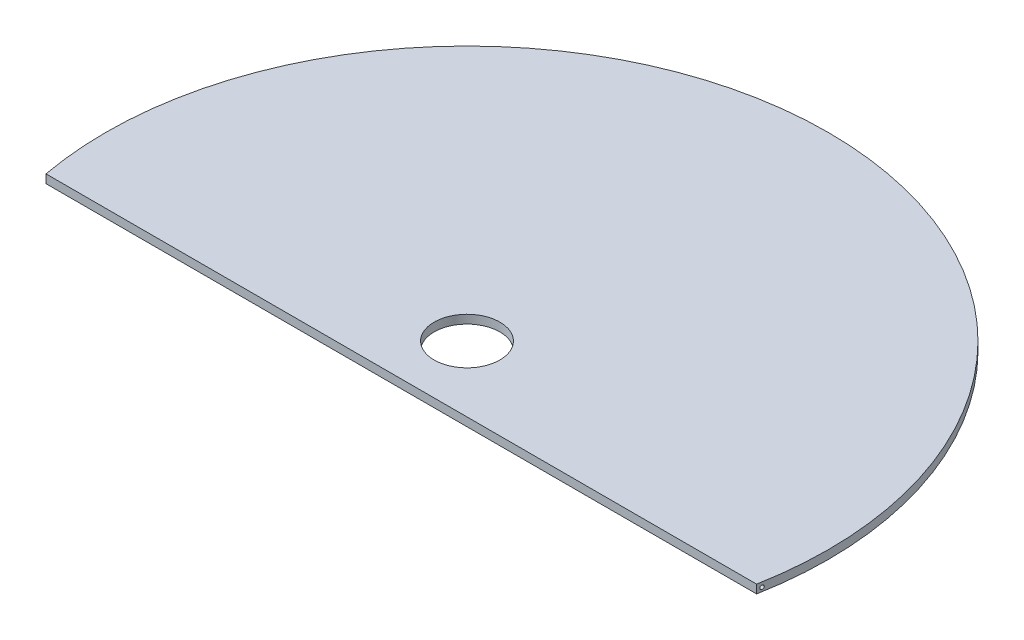
from build123d import *

# Parameters (mm, degrees)
SKETCH1_R               = 12.7
BOSS_EXTRUDE2_DEPTH     = 3.302
SKETCH4_R               = 0.744786443
CUT_EXTRUDE4_DEPTH      = 140.7
CUT_EXTRUDE4_DEPTH_BACK = 140.7


with BuildPart() as part:
    # Sketch1 → Boss-Extrude2 (new body)
    with BuildSketch(Plane(origin=(0, 0, 0), x_dir=(1, 0, 0), z_dir=(0, 1, 0))):
        with BuildLine():
            ThreePointArc((139.7, 0), (-12.753253462, 139.116657975), (-137.371503595, -25.4))
            Line((-137.371503595, -25.4), (137.371503595, -25.4))
            ThreePointArc((137.371503595, -25.4), (139.116657975, -12.753253462), (139.7, 0))
        make_face()
        Circle(SKETCH1_R, mode=Mode.SUBTRACT)
    extrude(amount=BOSS_EXTRUDE2_DEPTH)

    # Sketch4 → Cut-Extrude4 (cut, two sides)
    with BuildSketch(Plane(origin=(0, 0, 0), x_dir=(0, 0, -1), z_dir=(1, 0, 0))) as cut_extrude4_sk:
        with Locations((-23.622, 1.524)):
            Circle(SKETCH4_R)
    extrude(amount=CUT_EXTRUDE4_DEPTH, mode=Mode.SUBTRACT)
    extrude(cut_extrude4_sk.sketch, amount=-CUT_EXTRUDE4_DEPTH_BACK, mode=Mode.SUBTRACT)


solid = part.part
